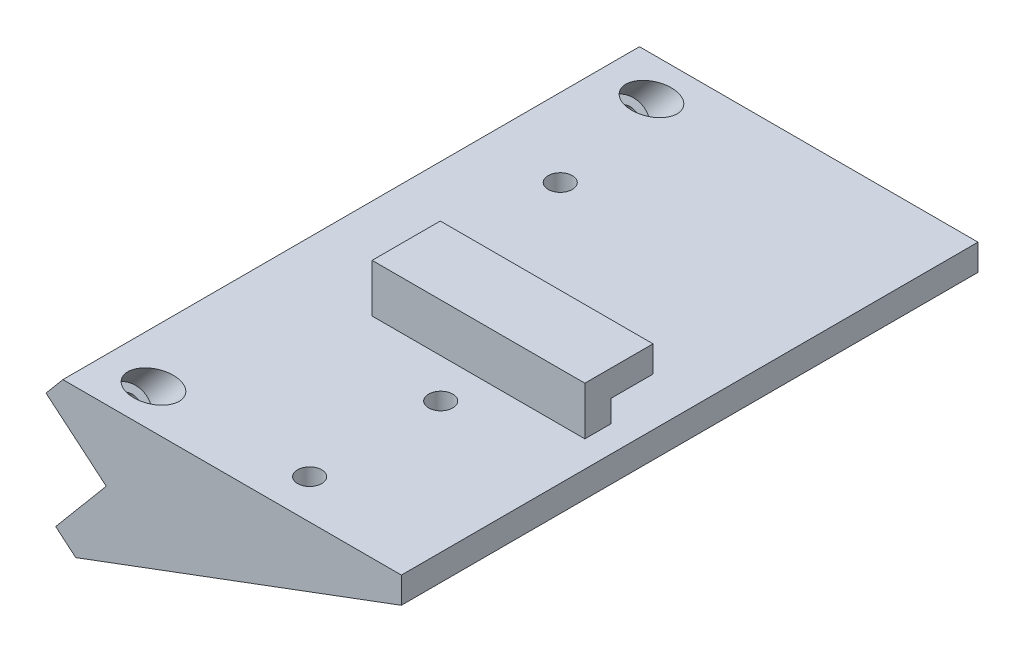
from build123d import *

# Parameters (mm, degrees)
EXTRUDE_1_DEPTH     = 65
EXTRUDE_2_DEPTH     = 5
EXTRUDE_4_DEPTH     = 8
SKETCH_9_R          = 2.3
CUT_EXTRUDE_4_DEPTH = 3.5
CUT_EXTRUDE_6_DEPTH = 14
EXTRUDE_5_DEPTH     = 40
HOLE_WIZARD_M4_1_D  = 4.5
CUT_EXTRUDE_START   = -3.5
SKETCH_17_R         = 3.75
CUT_EXTRUDE_7_DEPTH = 51.05954578
F_4_0MM_1_D         = 4.6
F_4_0MM_1_DEPTH     = 3.5
CUT_EXTRUDE_8_DEPTH = 5


with BuildPart() as part:
    # ｽｹｯﾁ1 → ﾎﾞｽ - 押し出し1 (new body)
    with BuildSketch(Plane.XY):
        Polygon((0, 0), (9.641814145, 11.490666647), (-1.848852501, 21.132480792), (1.365085547, 24.962703008), (65.946194887, 24.962703008), (65.946194887, 19.962703008), (3.830222216, -3.213938048), align=None)
    extrude(amount=EXTRUDE_1_DEPTH)

    # ｽｹｯﾁ6 → ﾎﾞｽ - 押し出し2 (add)
    with BuildSketch(Plane.XY.offset(65)):
        Polygon((0, 0), (3.830222216, -3.213938048), (65.946194887, 19.962703008), (65.946194887, 34.162703008), (9.084802154, 34.162703008), (-1.848852501, 21.132480792), (9.641814145, 11.490666647), align=None)
    extrude(amount=EXTRUDE_2_DEPTH)

    # ｽｹｯﾁ8 → ﾎﾞｽ - 押し出し4 (add)
    with BuildSketch(Plane(origin=(0, 0, 65), x_dir=(-1, 0, 0), z_dir=(0, 0, -1))):
        Polygon((-65.946194887, 34.162703008), (-65.946194887, 29.162703008), (-4.889303998, 29.162703008), (-9.084802154, 34.162703008), align=None)
    extrude(amount=EXTRUDE_4_DEPTH)

    # ｽｹｯﾁ9 → ｶｯﾄ - 押し出し4 (cut)
    with BuildSketch(Plane(origin=(0, 24.962703008, 0), x_dir=(1, 0, 0), z_dir=(0, 1, 0))):
        with Locations((16.255085547, -30)):
            Circle(SKETCH_9_R)
    extrude(amount=-CUT_EXTRUDE_4_DEPTH, mode=Mode.SUBTRACT)

    # ｽｹｯﾁ11 → ｶｯﾄ - 押し出し6 (cut, through all)
    with BuildSketch(Plane(origin=(0, 0, 57), x_dir=(-1, 0, 0), z_dir=(0, 0, -1))):
        Polygon((-1.365085547, 24.962703008), (-9.084802154, 34.162703008), (-20.364802154, 34.162703008), (-20.364802154, 24.962703008), align=None)
    extrude(amount=-CUT_EXTRUDE_6_DEPTH, mode=Mode.SUBTRACT)

    # ｽｹｯﾁ12 → ﾎﾞｽ - 押し出し5 (add)
    with BuildSketch(Plane.XY.offset(70)):
        Polygon((0, 0), (3.830222216, -3.213938048), (65.946194887, 19.962703008), (65.946194887, 24.962703008), (1.365085547, 24.962703008), (-1.848852501, 21.132480792), (9.641814145, 11.490666647), align=None)
    extrude(amount=EXTRUDE_5_DEPTH)

    # M4 すきま穴1 (through all)
    with Locations(Plane(origin=(9.641814145, 11.490666647, 0), x_dir=(-0.766044443, 0.64278761, 0), z_dir=(-0.64278761, -0.766044443, 0))):
        with Locations((7.5, -102.5), (7.5, -7.5)):
            Hole(HOLE_WIZARD_M4_1_D / 2)

    # ｽｹｯﾁ17 → ｶｯﾄ - 押し出し7 (cut, through all)
    with BuildSketch(Plane(origin=(9.641814145, 11.490666647, 0), x_dir=(0.766044443, -0.64278761, 0), z_dir=(-0.64278761, -0.766044443, 0)).offset(CUT_EXTRUDE_START)):
        with Locations((-7.5, 102.5)):
            Circle(SKETCH_17_R)
        with Locations((-7.5, 7.5)):
            Circle(SKETCH_17_R)
    extrude(amount=-CUT_EXTRUDE_7_DEPTH, mode=Mode.SUBTRACT)

    # Ø4.0mm ﾀﾞｳｴﾙ穴1
    with Locations(Plane(origin=(0, 24.962703008, 0), x_dir=(1, 0, 0), z_dir=(0, 1, 0))):
        with Locations((40.946194887, -77.5), (40.946194887, -102.5)):
            Hole(F_4_0MM_1_D / 2, depth=F_4_0MM_1_DEPTH)

    # ｽｹｯﾁ20 → ｶｯﾄ - 押し出し8 (cut)
    with BuildSketch(Plane(origin=(65.946194887, 0, 0), x_dir=(0, 0, -1), z_dir=(1, 0, 0))):
        Polygon((-70, 24.962703008), (-65, 24.962703008), (-65, 29.162703008), (-57, 29.162703008), (-57, 34.162703008), (-70, 34.162703008), align=None)
    extrude(amount=-CUT_EXTRUDE_8_DEPTH, mode=Mode.SUBTRACT)


solid = part.part
